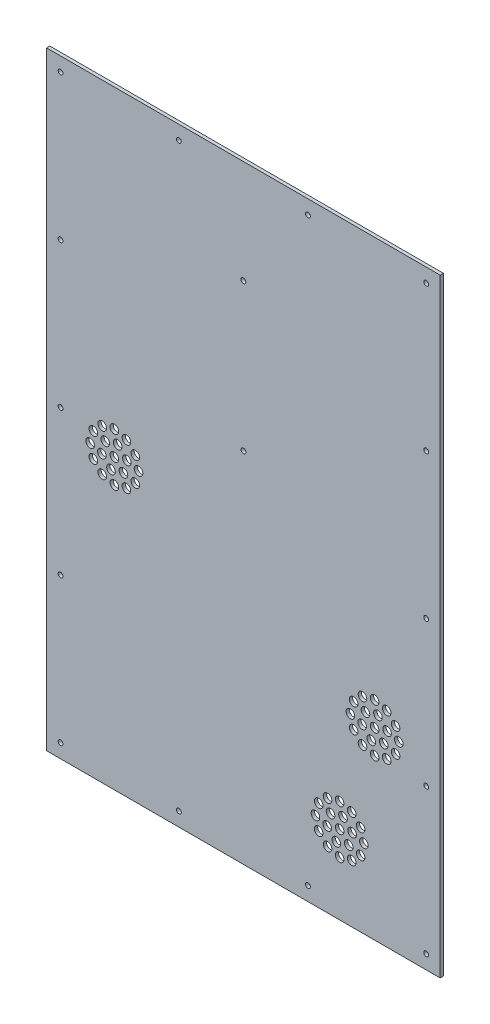
from build123d import *

# Parameters (mm, degrees)
SKETCH_1_W               = 366
SKETCH_1_H               = 566
EXTRUDE_1_DEPTH          = 3
SKETCH_5_R               = 2.25
CUT_EXTRUDE_2_DEPTH      = 4
SKETCH_8_R               = 4
CUT_EXTRUDE_5_DEPTH      = 4
CUT_EXTRUDE_5_DEPTH_BACK = 10
SKETCH_10_R              = 2.25
CUT_EXTRUDE_6_DEPTH      = 4
SKETCH_11_R              = 4
CUT_EXTRUDE_7_DEPTH      = 4


with BuildPart() as part:
    # Эскиз1 → Бобышка-Вытянуть1 (new body)
    with BuildSketch(Plane.XY):
        with Locations((183, 283)):
            Rectangle(SKETCH_1_W, SKETCH_1_H)
    extrude(amount=EXTRUDE_1_DEPTH)

    # Эскиз5 → Вырез-Вытянуть2 (cut, through all)
    with BuildSketch(Plane(origin=(0, 0, 0), x_dir=(-1, 0, 0), z_dir=(0, 0, -1))):
        with Locations((-353, 553)):
            Circle(SKETCH_5_R)
        with Locations((-13, 553)):
            Circle(SKETCH_5_R)
        with Locations((-243, 553)):
            Circle(SKETCH_5_R)
        with Locations((-123, 553)):
            Circle(SKETCH_5_R)
        with Locations((-353, 418)):
            Circle(SKETCH_5_R)
        with Locations((-353, 283)):
            Circle(SKETCH_5_R)
        with Locations((-353, 148)):
            Circle(SKETCH_5_R)
        with Locations((-353, 13)):
            Circle(SKETCH_5_R)
        with Locations((-123, 13)):
            Circle(SKETCH_5_R)
        with Locations((-243, 13)):
            Circle(SKETCH_5_R)
        with Locations((-13, 418)):
            Circle(SKETCH_5_R)
        with Locations((-13, 283)):
            Circle(SKETCH_5_R)
        with Locations((-13, 148)):
            Circle(SKETCH_5_R)
        with Locations((-13, 13)):
            Circle(SKETCH_5_R)
    extrude(amount=-CUT_EXTRUDE_2_DEPTH, mode=Mode.SUBTRACT)

    # Эскиз8 → Вырез-Вытянуть5 (cut, two sides)
    with BuildSketch(Plane.XY) as cut_extrude_5_sk:
        with Locations((305, 148.5)):
            Circle(SKETCH_8_R)
        with Locations((313.485281374, 162.514718626)):
            Circle(SKETCH_8_R)
        with Locations((305, 171)):
            Circle(SKETCH_8_R)
        with Locations((293.75, 151.514428415)):
            Circle(SKETCH_8_R)
        with Locations((285.514428415, 159.75)):
            Circle(SKETCH_8_R)
        with Locations((282.5, 171)):
            Circle(SKETCH_8_R)
        with Locations((285.514428415, 182.25)):
            Circle(SKETCH_8_R)
        with Locations((293.75, 190.485571585)):
            Circle(SKETCH_8_R)
        with Locations((305, 193.5)):
            Circle(SKETCH_8_R)
        with Locations((316.25, 190.485571585)):
            Circle(SKETCH_8_R)
        with Locations((324.485571585, 182.25)):
            Circle(SKETCH_8_R)
        with Locations((327.5, 171)):
            Circle(SKETCH_8_R)
        with Locations((324.485571585, 159.75)):
            Circle(SKETCH_8_R)
        with Locations((316.25, 151.514428415)):
            Circle(SKETCH_8_R)
        with Locations((301.894171459, 159.408890085)):
            Circle(SKETCH_8_R)
        with Locations((293.408890085, 167.894171459)):
            Circle(SKETCH_8_R)
        with Locations((296.514718626, 179.485281374)):
            Circle(SKETCH_8_R)
        with Locations((308.105828541, 182.591109915)):
            Circle(SKETCH_8_R)
        with Locations((316.591109915, 174.105828541)):
            Circle(SKETCH_8_R)
        with Locations((272.5, 73)):
            Circle(SKETCH_8_R)
        with Locations((272.5, 50.5)):
            Circle(SKETCH_8_R)
        with Locations((280.985281374, 64.514718626)):
            Circle(SKETCH_8_R)
        with Locations((261.25, 53.514428415)):
            Circle(SKETCH_8_R)
        with Locations((253.014428415, 61.75)):
            Circle(SKETCH_8_R)
        with Locations((250, 73)):
            Circle(SKETCH_8_R)
        with Locations((253.014428415, 84.25)):
            Circle(SKETCH_8_R)
        with Locations((261.25, 92.485571585)):
            Circle(SKETCH_8_R)
        with Locations((272.5, 95.5)):
            Circle(SKETCH_8_R)
        with Locations((283.75, 92.485571585)):
            Circle(SKETCH_8_R)
        with Locations((291.985571585, 84.25)):
            Circle(SKETCH_8_R)
        with Locations((295, 73)):
            Circle(SKETCH_8_R)
        with Locations((291.985571585, 61.75)):
            Circle(SKETCH_8_R)
        with Locations((283.75, 53.514428415)):
            Circle(SKETCH_8_R)
        with Locations((269.394171459, 61.408890085)):
            Circle(SKETCH_8_R)
        with Locations((260.908890085, 69.894171459)):
            Circle(SKETCH_8_R)
        with Locations((264.014718626, 81.485281374)):
            Circle(SKETCH_8_R)
        with Locations((275.605828541, 84.591109915)):
            Circle(SKETCH_8_R)
        with Locations((284.091109915, 76.105828541)):
            Circle(SKETCH_8_R)
    extrude(amount=CUT_EXTRUDE_5_DEPTH, mode=Mode.SUBTRACT)
    extrude(cut_extrude_5_sk.sketch, amount=-CUT_EXTRUDE_5_DEPTH_BACK, mode=Mode.SUBTRACT)

    # Эскиз10 → Вырез-Вытянуть6 (cut, through all)
    with BuildSketch(Plane.XY.offset(3)):
        with Locations((183, 470)):
            Circle(SKETCH_10_R)
        with Locations((183, 333)):
            Circle(SKETCH_10_R)
    extrude(amount=-CUT_EXTRUDE_6_DEPTH, mode=Mode.SUBTRACT)

    # Эскиз11 → Вырез-Вытянуть7 (cut, through all)
    with BuildSketch(Plane(origin=(0, 0, 0), x_dir=(-1, 0, 0), z_dir=(0, 0, -1))):
        with Locations((-63, 268)):
            Circle(SKETCH_11_R)
        with Locations((-63, 245.5)):
            Circle(SKETCH_11_R)
        with Locations((-71.485281374, 259.514718626)):
            Circle(SKETCH_11_R)
        with Locations((-74.25, 248.514428415)):
            Circle(SKETCH_11_R)
        with Locations((-82.485571585, 256.75)):
            Circle(SKETCH_11_R)
        with Locations((-85.5, 268)):
            Circle(SKETCH_11_R)
        with Locations((-82.485571585, 279.25)):
            Circle(SKETCH_11_R)
        with Locations((-74.25, 287.485571585)):
            Circle(SKETCH_11_R)
        with Locations((-63, 290.5)):
            Circle(SKETCH_11_R)
        with Locations((-51.75, 287.485571585)):
            Circle(SKETCH_11_R)
        with Locations((-43.514428415, 279.25)):
            Circle(SKETCH_11_R)
        with Locations((-40.5, 268)):
            Circle(SKETCH_11_R)
        with Locations((-43.514428415, 256.75)):
            Circle(SKETCH_11_R)
        with Locations((-51.75, 248.514428415)):
            Circle(SKETCH_11_R)
        with Locations((-74.591109915, 271.105828541)):
            Circle(SKETCH_11_R)
        with Locations((-66.105828541, 279.591109915)):
            Circle(SKETCH_11_R)
        with Locations((-54.514718626, 276.485281374)):
            Circle(SKETCH_11_R)
        with Locations((-51.408890085, 264.894171459)):
            Circle(SKETCH_11_R)
        with Locations((-59.894171459, 256.408890085)):
            Circle(SKETCH_11_R)
    extrude(amount=-CUT_EXTRUDE_7_DEPTH, mode=Mode.SUBTRACT)


solid = part.part
